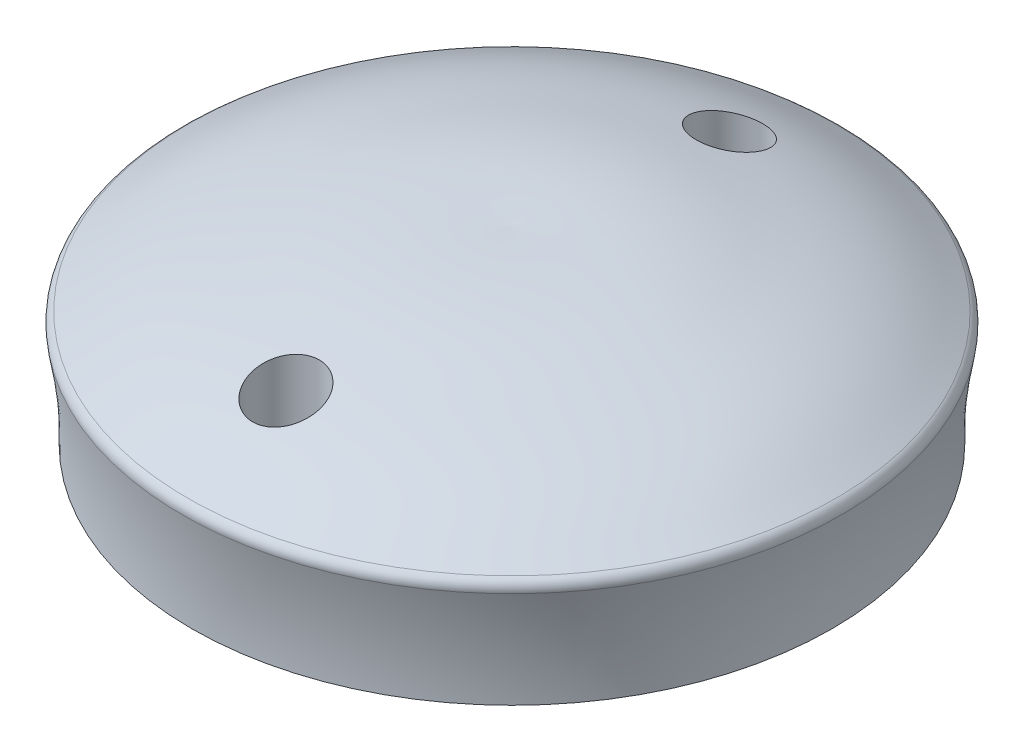
from build123d import *

# Parameters (mm, degrees)
SKIZZE2_W                       = 10.3
SKIZZE2_H                       = 25
SCHNITT_LINEAR_AUSTRAGEN1_DEPTH = 6.5
SKIZZE2_3_R                     = 1.5
SCHNITT_LINEAR_AUSTRAGEN2_DEPTH = 12
VERRUNDUNG2_R                   = 1
SCHNITT_LINEAR_START            = -3
SKIZZE3_R                       = 3
SCHNITT_LINEAR_AUSTRAGEN3_DEPTH = 20


with BuildPart() as part:
    # Skizze1 → Rotation1 (revolve)
    with BuildSketch(Plane(origin=(0, 0, 0), x_dir=(0, 0, -1), z_dir=(1, 0, 0))):
        with BuildLine():
            Line((0.380209453, 10.098852641), (29.260449341, 10.098852641))
            add(Edge.make_bspline(
                [(30.229832566, 20.098852641), (29.459408859, 16.453481859), (29.174419435, 13.222363479), (29.260449341, 10.098852641)],
                knots=[0, 0, 0, 0, 0.538089657, 0.538089657, 0.538089657, 0.538089657], degree=3))
            add(Edge.make_bspline(
                [(0.380209453, 27.098852641), (8.631239306, 27.522835578), (14.31203294, 26.20206954), (24.747590137, 23.636635194), (27.076755658, 21.866114077), (30.229832566, 20.098852641)],
                knots=[0, 0, 0, 0, 0.318831446, 0.418831446, 1, 1, 1, 1], degree=3))
            Line((0.380209453, 27.098852641), (0.380209453, 10.098852641))
        make_face()
    revolve(axis=Axis((0, 5.098852641, -0.380209453), (0, 1, 0)))

    # Skizze2 → Schnitt-Linear austragen1 (cut)
    with BuildSketch(Plane.XZ.offset(-10.098852641)):
        Rectangle(SKIZZE2_W, SKIZZE2_H)
    extrude(amount=-SCHNITT_LINEAR_AUSTRAGEN1_DEPTH, mode=Mode.SUBTRACT)

    # Skizze2_3 → Schnitt-Linear austragen2 (cut)
    with BuildSketch(Plane.XZ.offset(-10.098852641)):
        with Locations((0, -20)):
            Circle(SKIZZE2_3_R)
        with Locations((0, 20)):
            Circle(SKIZZE2_3_R)
    extrude(amount=-SCHNITT_LINEAR_AUSTRAGEN2_DEPTH, mode=Mode.SUBTRACT)

    # Verrundung2
    verrundung2_edges = [part.edges().sort_by_distance(p)[0] for p in [
        (0, 20.098852641, 29.46941366),
    ]]
    fillet(verrundung2_edges, radius=VERRUNDUNG2_R)

    # Skizze3 → Schnitt-Linear austragen3 (cut)
    with BuildSketch(Plane.XZ.offset(-10.098852641).offset(SCHNITT_LINEAR_START)):
        with Locations((0, -20)):
            Circle(SKIZZE3_R)
        with Locations((0, 20)):
            Circle(SKIZZE3_R)
    extrude(amount=-SCHNITT_LINEAR_AUSTRAGEN3_DEPTH, mode=Mode.SUBTRACT)


solid = part.part
